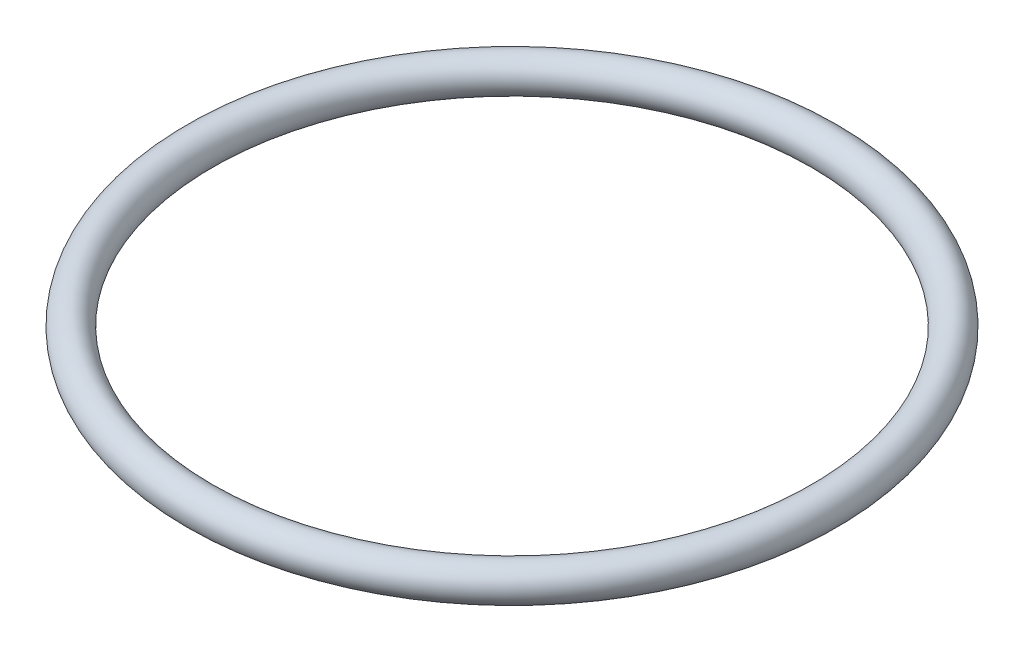
from build123d import *

# Parameters (mm, degrees)
SKETCH1_R = 2


with BuildPart() as part:
    # Sketch1 → Revolve1 (revolve)
    with BuildSketch(Plane.XY):
        with Locations((-35.5, 0)):
            Circle(SKETCH1_R)
    revolve(axis=Axis((0, 0, 0), (0, 1, 0)))


solid = part.part
